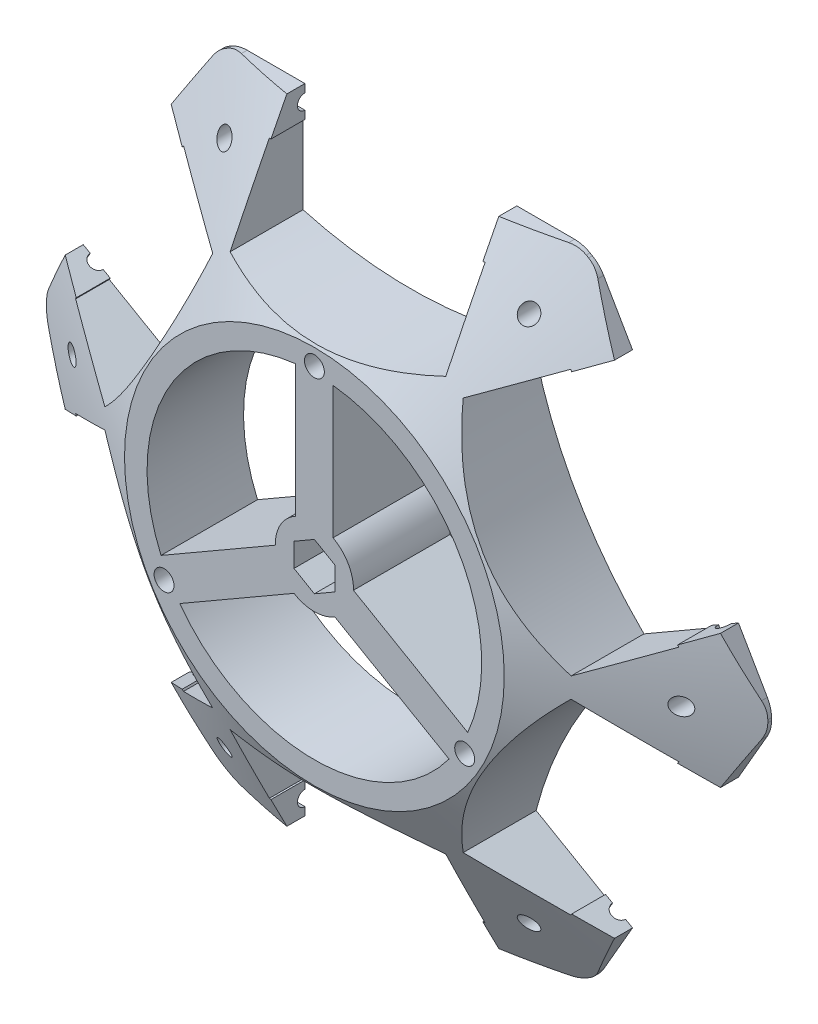
from build123d import *

# Parameters (mm, degrees)
SKETCH3_R                = 57.933922807
DISK_DEPTH               = 0.6
SKETCH16_R               = 57.933922807
SKETCH17_R               = 30.5
ROLLER_REACH             = 85.384
WASHERS_REACH            = 85.384
SKETCH9_W                = 0.3
SKETCH9_H                = 5
TRIM_TIPS_DEPTH          = 84.384224226
FILLET2_R                = 5
SKETCH5_W                = 49.8
SKETCH5_H                = 1.2
SHAFT_ANGLE              = 180
CIRPATTERN6_COUNT        = 6
FILLET2_OF_CIRPATTERN6_R = 5
SKETCH11_R               = 1.6
HUB_SCREW_DEPTH          = 79.686042075
CIRPATTERN3_COUNT        = 3
HUB_DEPTH                = 79.686042075
SHAFT_SCREWS_REACH       = 80.686
SKETCH13_R               = 1.4
CIRPATTERN5_COUNT        = 6
RIBS_Y_REACH             = 80.686
CIRPATTERN7_COUNT        = 3


with BuildPart() as part:
    # Sketch3 → Disk (new body)
    with BuildSketch(Plane.XY):
        Circle(SKETCH3_R)
    extrude(amount=DISK_DEPTH)

    # Sketch16 → Loft1 section 0
    with BuildSketch(Plane.XY.offset(0.6)):
        Circle(SKETCH16_R)
    # Sketch17 → Loft1 section 1
    with BuildSketch(Plane.XY.offset(15.5)):
        Circle(SKETCH17_R)
    loft()

    # Roller: up to this cone (the profile starts inside it)
    roller_end = Plane(origin=(0, 0, 0), z_dir=(0, 0, -1)).offset(-32.065256663) * Cone(1.841e-06, 325.870633993, 176.987901193, align=(Align.CENTER, Align.CENTER, Align.MIN), mode=Mode.PRIVATE)
    # Sketch8 → Roller (cut, up to the surface)
    with BuildSketch(Plane.XY, mode=Mode.PRIVATE) as roller_sk1:
        with BuildLine():
            Line((17.323237932, 62.649065656), (17.323237932, 33.231330512))
            ThreePointArc((17.323237932, 33.231330512), (0, 30.880396168), (-17.323237932, 33.231330512))
            Line((-17.323237932, 33.231330512), (-17.323237932, 62.649065656))
            ThreePointArc((-17.323237932, 62.649065656), (0, 65), (17.323237932, 62.649065656))
        make_face()
    roller_tool1 = extrude(roller_sk1.sketch, amount=ROLLER_REACH, mode=Mode.PRIVATE) & roller_end
    roller = roller_tool1.solids().sort_by_distance((0, 47.940198, 0))[0]
    add(roller, mode=Mode.SUBTRACT)

    # Washers: up to this cone (the profile starts inside it)
    washers_end = Plane(origin=(0, 0, 0), z_dir=(0, 0, -1)).offset(-32.065256663) * Cone(1.841e-06, 325.870633993, 176.987901193, align=(Align.CENTER, Align.CENTER, Align.MIN), mode=Mode.PRIVATE)
    # Sketch9 → Washers (add, up to the surface)
    with BuildSketch(Plane.XY, mode=Mode.PRIVATE) as washers_sk1:
        with Locations((17.173237932, 48.440198084)):
            Rectangle(SKETCH9_W, SKETCH9_H)
    washers_tool1 = extrude(washers_sk1.sketch, amount=WASHERS_REACH, mode=Mode.PRIVATE) & washers_end
    # Sketch9 → Washers (add, up to the surface)
    with BuildSketch(Plane.XY, mode=Mode.PRIVATE) as washers_sk2:
        with Locations((-17.173237932, 48.440198084)):
            Rectangle(SKETCH9_W, SKETCH9_H)
    washers_tool2 = extrude(washers_sk2.sketch, amount=WASHERS_REACH, mode=Mode.PRIVATE) & washers_end
    washers = washers_tool1.solids().sort_by_distance((17.173238, 48.440198, 0))[0] + washers_tool2.solids().sort_by_distance((-17.173238, 48.440198, 0))[0]
    add(washers)

    # Sketch19 → Trim tips (cut, through all)
    with BuildSketch(Plane.XY):
        with BuildLine():
            Line((17.323237932, 50.940198084), (27.594123123, 50.940198084))
            ThreePointArc((27.594123123, 50.940198084), (22.56342163, 53.359454796), (17.323237932, 55.283314294))
            Line((17.323237932, 55.283314294), (17.323237932, 50.940198084))
        make_face()
        with BuildLine():
            Line((-17.323237932, 55.283314294), (-17.323237932, 50.940198084))
            Line((-17.323237932, 50.940198084), (-27.594123123, 50.940198084))
            ThreePointArc((-27.594123123, 50.940198084), (-22.56342163, 53.359454796), (-17.323237932, 55.283314294))
        make_face()
    trim_tips = extrude(amount=TRIM_TIPS_DEPTH, mode=Mode.SUBTRACT)

    # Fillet2
    fillet2_edges = [part.edges().sort_by_distance(p)[0] for p in [
        (-27.594123123, 50.940198084, 0.3),
        (27.594123123, 50.940198084, 0.3),
    ]]
    fillet(fillet2_edges, radius=FILLET2_R)

    # Sketch5 → Shaft (revolve, cut)
    with BuildSketch(Plane.XY):
        with Locations((0, 49.040198084)):
            Rectangle(SKETCH5_W, SKETCH5_H)
    shaft = revolve(axis=Axis((24.9, 48.440198084, 0), (1, 0, 0)), revolution_arc=SHAFT_ANGLE, mode=Mode.SUBTRACT)

    # CirPattern6: Roller, Washers, Trim tips, Shaft ×6 about axis
    cirpattern6_axis = Axis((0, 0, 0), (0, 0, 1))
    add([roller.rotate(cirpattern6_axis, i * 360 / CIRPATTERN6_COUNT) for i in range(1, CIRPATTERN6_COUNT)], mode=Mode.SUBTRACT)
    add([washers.rotate(cirpattern6_axis, i * 360 / CIRPATTERN6_COUNT) for i in range(1, CIRPATTERN6_COUNT)])
    add([trim_tips.rotate(cirpattern6_axis, i * 360 / CIRPATTERN6_COUNT) for i in range(1, CIRPATTERN6_COUNT)], mode=Mode.SUBTRACT)
    add([shaft.rotate(cirpattern6_axis, i * 360 / CIRPATTERN6_COUNT) for i in range(1, CIRPATTERN6_COUNT)], mode=Mode.SUBTRACT)

    # Fillet2 of CirPattern6
    fillet2_of_cirpattern6_edges = [part.edges().sort_by_distance(p)[0] for p in [
        (-57.912567176, 1.572887422, 0.3),
        (-30.318444053, 49.367310662, 0.3),
        (-30.318444053, -49.367310662, 0.3),
        (-57.912567176, -1.572887422, 0.3),
        (27.594123123, -50.940198084, 0.3),
        (-27.594123123, -50.940198084, 0.3),
        (57.912567176, -1.572887422, 0.3),
        (30.318444053, -49.367310662, 0.3),
        (30.318444053, 49.367310662, 0.3),
        (57.912567176, 1.572887422, 0.3),
    ]]
    fillet(fillet2_of_cirpattern6_edges, radius=FILLET2_OF_CIRPATTERN6_R)

    # Sketch11 → Hub screw (cut, through all)
    with BuildSketch(Plane.XY):
        with Locations((-24.145131349, -13.940198084)):
            Circle(SKETCH11_R)
    hub_screw = extrude(amount=HUB_SCREW_DEPTH, mode=Mode.SUBTRACT)

    # CirPattern3: Hub screw ×3 about axis
    cirpattern3_axis = Axis((0, 0, 0), (0, 0, 1))
    for i in range(1, CIRPATTERN3_COUNT):
        add(hub_screw.rotate(cirpattern3_axis, i * 360 / CIRPATTERN3_COUNT), mode=Mode.SUBTRACT)

    # Sketch12 → Hub (cut, through all)
    with BuildSketch(Plane.XY):
        Polygon((-3.275, -1.890822132), (0, -3.781644263), (3.275, -1.890822132), (3.275, 1.890822132), (0, 3.781644263), (-3.275, 1.890822132), align=None)
    extrude(amount=HUB_DEPTH, mode=Mode.SUBTRACT)

    # Shaft screws: up to this cone (the profile starts inside it)
    shaft_screws_end = Plane(origin=(0, 0, 0), z_dir=(0, 0, -1)).offset(-32.065256663) * Cone(1.841e-06, 317.220662896, 172.289901193, align=(Align.CENTER, Align.CENTER, Align.MIN), mode=Mode.PRIVATE)
    # Sketch13 → Shaft screws (cut, up to the surface)
    with BuildSketch(Plane.XY, mode=Mode.PRIVATE) as shaft_screws_sk1:
        with Locations(Location((24.466961403, -42.378020257, 0), (0, 0, 232.867513174))):
            Circle(SKETCH13_R)
    shaft_screws_tool1 = extrude(shaft_screws_sk1.sketch, amount=SHAFT_SCREWS_REACH, mode=Mode.PRIVATE) & shaft_screws_end
    shaft_screws = shaft_screws_tool1.solids().sort_by_distance((24.466961, -42.37802, 0))[0]
    add(shaft_screws, mode=Mode.SUBTRACT)

    # CirPattern5: Shaft screws ×6 about axis
    cirpattern5_axis = Axis((0, 0, 0), (0, 0, 1))
    for i in range(1, CIRPATTERN5_COUNT):
        add(shaft_screws.rotate(cirpattern5_axis, i * 360 / CIRPATTERN5_COUNT), mode=Mode.SUBTRACT)

    # Sketch21 → Ribs _Y (cut, up to next)
    with BuildSketch(Plane.XY, mode=Mode.PRIVATE) as ribs_y_sk1:
        with BuildLine():
            Line((-3, 26.712463348), (-3, 5.511408622))
            ThreePointArc((-3, 5.511408622), (-5.434309409, 3.1375), (-6.273019877, -0.1576281))
            Line((-6.273019877, -0.1576281), (-24.633671857, -10.758155463))
            ThreePointArc((-24.633671857, -10.758155463), (-23.279105945, 13.440198084), (-3, 26.712463348))
        make_face()
    ribs_y_tool1 = extrude(ribs_y_sk1.sketch, amount=RIBS_Y_REACH, mode=Mode.PRIVATE) & part.part
    ribs_y = ribs_y_tool1.solids().sort_by_distance((-14.491463, 8.36665, 0))[0]
    add(ribs_y, mode=Mode.SUBTRACT)

    # CirPattern7: Ribs _Y ×3 about axis
    cirpattern7_axis = Axis((0, 0, 0), (0, 0, 1))
    for i in range(1, CIRPATTERN7_COUNT):
        add(ribs_y.rotate(cirpattern7_axis, i * 360 / CIRPATTERN7_COUNT), mode=Mode.SUBTRACT)


solid = part.part
